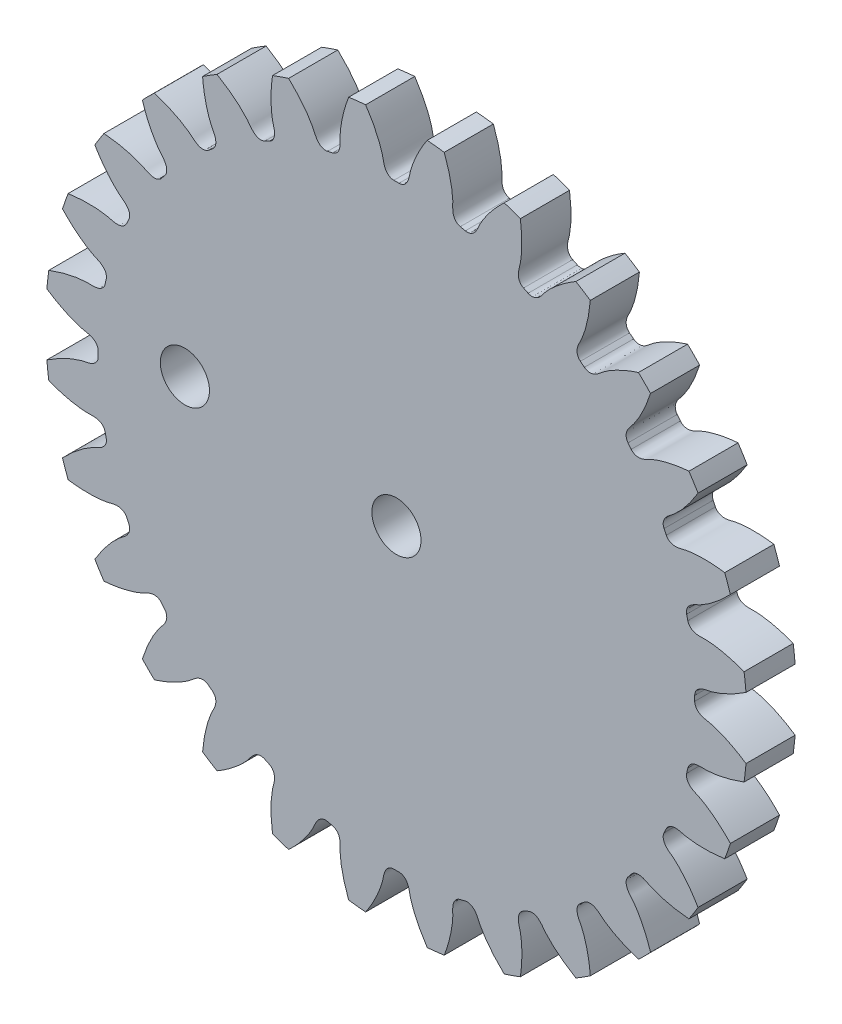
from build123d import *

# Parameters (mm, degrees)
GEAR_BASESKETCH_R                         = 21.428571429
COMPANY_STANDARD_1_40_0000MM_P_D_DEPTH    = 1.5
TOOTH_CUT_D_P_17_7800_P_A_20_000DEG_DEPTH = 31.341676732
TOOTH_PATTERN_28_28_COUNT                 = 28
SKETCH1_R                                 = 1.5
CUT_EXTRUDE2_DEPTH                        = 31.336459253


with BuildPart() as part:
    # Gear-BaseSketch → Company Standard _1_ 40.0000mm P.D (new, symmetric)
    with BuildSketch(Plane.XY):
        Circle(GEAR_BASESKETCH_R)
    extrude(amount=COMPANY_STANDARD_1_40_0000MM_P_D_DEPTH, both=True)

    # Tooth-Sketch_ Backlash_ 0.0000mm → Tooth-Cut_ D.P._17.7800_ P.A._20.000deg (cut, symmetric)
    with BuildSketch(Plane.XY):
        with BuildLine():
            ThreePointArc((-1.941515883, 21.437443045), (0, 21.525181724), (1.941515883, 21.437443045))
            add(Edge.make_bspline(
                [(1.941515883, 21.437443045), (1.804383903, 21.236772748), (1.61597143, 20.939630853), (1.396648333, 20.544995883), (1.260965885, 20.277945397), (1.146222447, 20.029683932), (1.050818251, 19.801367101), (0.973092052, 19.594057565), (0.911347249, 19.408719448), (0.86379375, 19.246225427), (0.828741644, 19.107326597), (0.806553264, 19.004305484), (0.793873619, 18.93331407), (0.785294902, 18.886826481), (0.776304045, 18.845094375), (0.760127999, 18.778188715), (0.732872274, 18.687588776), (0.686082538, 18.575119592), (0.622527219, 18.465371892), (0.531261821, 18.357199811), (0.380490672, 18.247605564), (0.240757521, 18.214046733), (0.156605949, 18.213612455)],
                knots=[0, 0, 0, 0, 0.190811628, 0.275995392, 0.354364454, 0.425918816, 0.490658478, 0.548583439, 0.5996937, 0.64398926, 0.681470121, 0.712136282, 0.726696296, 0.738084041, 0.749246412, 0.760204972, 0.792121225, 0.823409511, 0.855638661, 0.891318039, 0.933790828, 1, 1, 1, 1], degree=3))
            ThreePointArc((0.156605949, 18.213612455), (0, 18.214285714), (-0.156605949, 18.213612455))
            add(Edge.make_bspline(
                [(-1.941515883, 21.437443045), (-1.804383903, 21.236772748), (-1.61597143, 20.939630853), (-1.396648333, 20.544995883), (-1.260965885, 20.277945397), (-1.146222447, 20.029683932), (-1.050818251, 19.801367101), (-0.973092052, 19.594057565), (-0.911347249, 19.408719448), (-0.86379375, 19.246225427), (-0.828741644, 19.107326597), (-0.806553264, 19.004305484), (-0.793873619, 18.93331407), (-0.785294902, 18.886826481), (-0.776304045, 18.845094375), (-0.760127999, 18.778188715), (-0.732872274, 18.687588776), (-0.686082538, 18.575119592), (-0.622527219, 18.465371892), (-0.531261821, 18.357199811), (-0.380490672, 18.247605564), (-0.240757521, 18.214046733), (-0.156605949, 18.213612455)],
                knots=[0, 0, 0, 0, 0.190811628, 0.275995392, 0.354364454, 0.425918816, 0.490658478, 0.548583439, 0.5996937, 0.64398926, 0.681470121, 0.712136282, 0.726696296, 0.738084041, 0.749246412, 0.760204972, 0.792121225, 0.823409511, 0.855638661, 0.891318039, 0.933790828, 1, 1, 1, 1], degree=3))
        make_face()
    tooth_cut_d_p_17_7800_p_a_20_000deg = extrude(amount=TOOTH_CUT_D_P_17_7800_P_A_20_000DEG_DEPTH, both=True, mode=Mode.SUBTRACT)

    # Tooth Pattern_ 28 _ 28: Tooth-Cut_ D.P._17.7800_ P.A._20.000deg ×28 about axis
    tooth_pattern_28_28_axis = Axis((0, 0, -88.99), (0, 0, 1))
    for i in range(1, TOOTH_PATTERN_28_28_COUNT):
        add(tooth_cut_d_p_17_7800_p_a_20_000deg.rotate(tooth_pattern_28_28_axis, i * 360 / TOOTH_PATTERN_28_28_COUNT), mode=Mode.SUBTRACT)

    # Sketch1 → Cut-Extrude2 (cut, through all)
    with BuildSketch(Plane.XY.offset(1.5)):
        Circle(SKETCH1_R)
        with Locations((-12.918258729, 1.455538189)):
            Circle(SKETCH1_R)
    extrude(amount=-CUT_EXTRUDE2_DEPTH, mode=Mode.SUBTRACT)


solid = part.part
